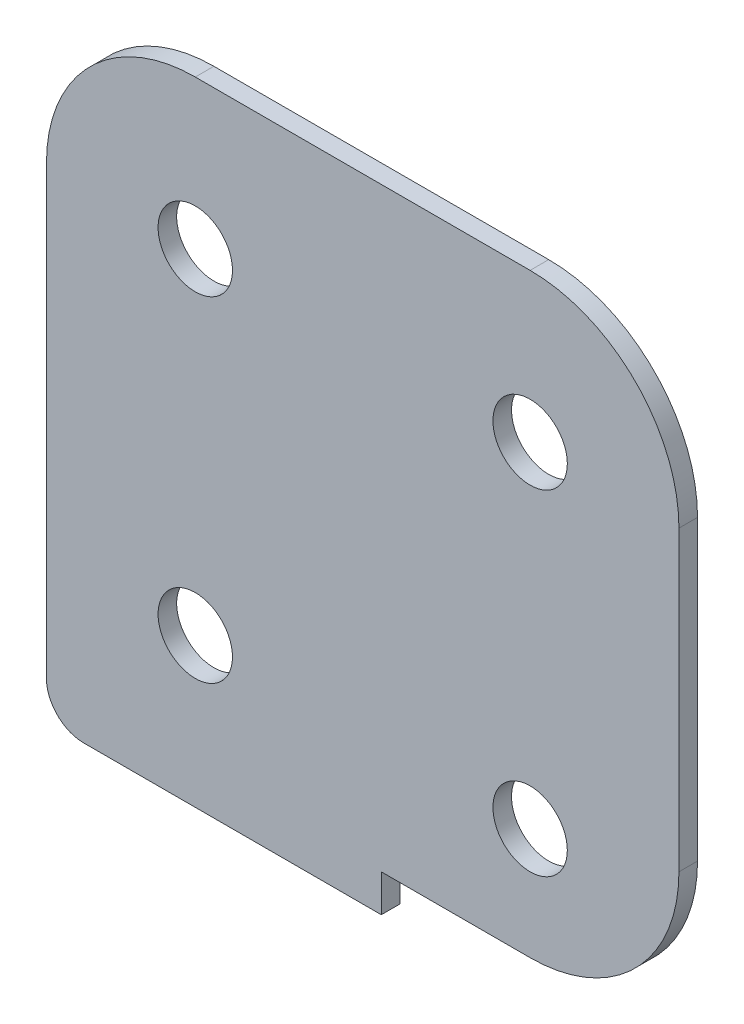
from build123d import *

# Parameters (mm, degrees)
SKETCH1_R           = 3.175
BOSS_EXTRUDE1_DEPTH = 1.5875
FILLET1_R           = 3.175


with BuildPart() as part:
    # Sketch1 → Boss-Extrude1 (new body)
    with BuildSketch(Plane.XY):
        with BuildLine():
            ThreePointArc((-12.7, 0), (-3.719743879, 3.719743879), (0, 12.7))
            Line((0, 12.7), (0, 38.1))
            ThreePointArc((0, 38.1), (-3.719743879, 47.080256121), (-12.7, 50.8))
            Line((-12.7, 50.8), (-41.275, 50.8))
            ThreePointArc((-41.275, 50.8), (-50.255256121, 47.080256121), (-53.975, 38.1))
            Line((-53.975, 38.1), (-53.975, 0))
            Line((-53.975, 0), (-53.975, -3.175))
            Line((-53.975, -3.175), (-25.4, -3.175))
            Line((-25.4, -3.175), (-25.4, 0))
            Line((-25.4, 0), (-12.7, 0))
        make_face()
        with Locations((-41.275, 9.525)):
            Circle(SKETCH1_R, mode=Mode.SUBTRACT)
        with Locations((-12.7, 9.525)):
            Circle(SKETCH1_R, mode=Mode.SUBTRACT)
        with Locations((-41.275, 38.1)):
            Circle(SKETCH1_R, mode=Mode.SUBTRACT)
        with Locations((-12.7, 38.1)):
            Circle(SKETCH1_R, mode=Mode.SUBTRACT)
    extrude(amount=BOSS_EXTRUDE1_DEPTH)

    # Fillet1
    fillet1_edges = [part.edges().sort_by_distance(p)[0] for p in [
        (-53.975, -3.175, 0.79375),
    ]]
    fillet(fillet1_edges, radius=FILLET1_R)


solid = part.part
